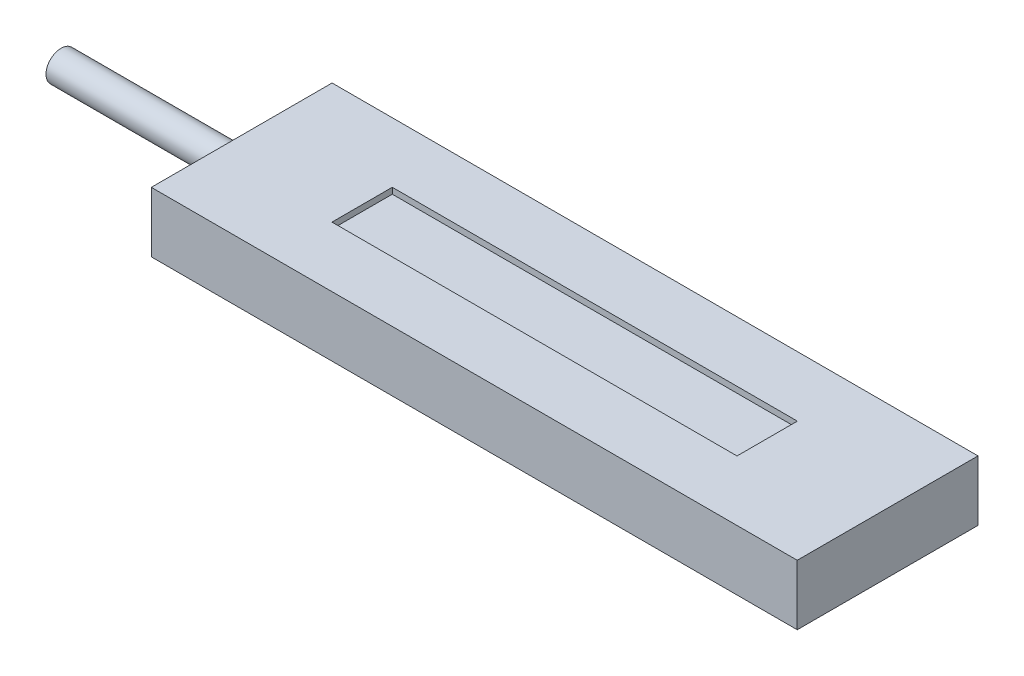
from build123d import *

# Parameters (mm, degrees)
SKETCH1_W           = 107.27
SKETCH1_H           = 30.02
BOSS_EXTRUDE1_DEPTH = 10
SKETCH2_R           = 2.5
BOSS_EXTRUDE2_DEPTH = 30
SKETCH3_W           = 67.27
SKETCH3_H           = 10.02
CUT_EXTRUDE1_DEPTH  = 1


with BuildPart() as part:
    # Sketch1 → Boss-Extrude1 (new body)
    with BuildSketch(Plane(origin=(0, 0, 0), x_dir=(1, 0, 0), z_dir=(0, 1, 0))):
        with Locations((53.635, 15.01)):
            Rectangle(SKETCH1_W, SKETCH1_H)
    extrude(amount=BOSS_EXTRUDE1_DEPTH)

    # Sketch2 → Boss-Extrude2 (add)
    with BuildSketch(Plane.ZY):
        with Locations((-15.01, 5)):
            Circle(SKETCH2_R)
    extrude(amount=BOSS_EXTRUDE2_DEPTH)

    # Sketch3 → Cut-Extrude1 (cut)
    with BuildSketch(Plane(origin=(0, 10, 0), x_dir=(1, 0, 0), z_dir=(0, 1, 0))):
        with Locations((53.635, 15.01)):
            Rectangle(SKETCH3_W, SKETCH3_H)
    extrude(amount=-CUT_EXTRUDE1_DEPTH, mode=Mode.SUBTRACT)


solid = part.part
